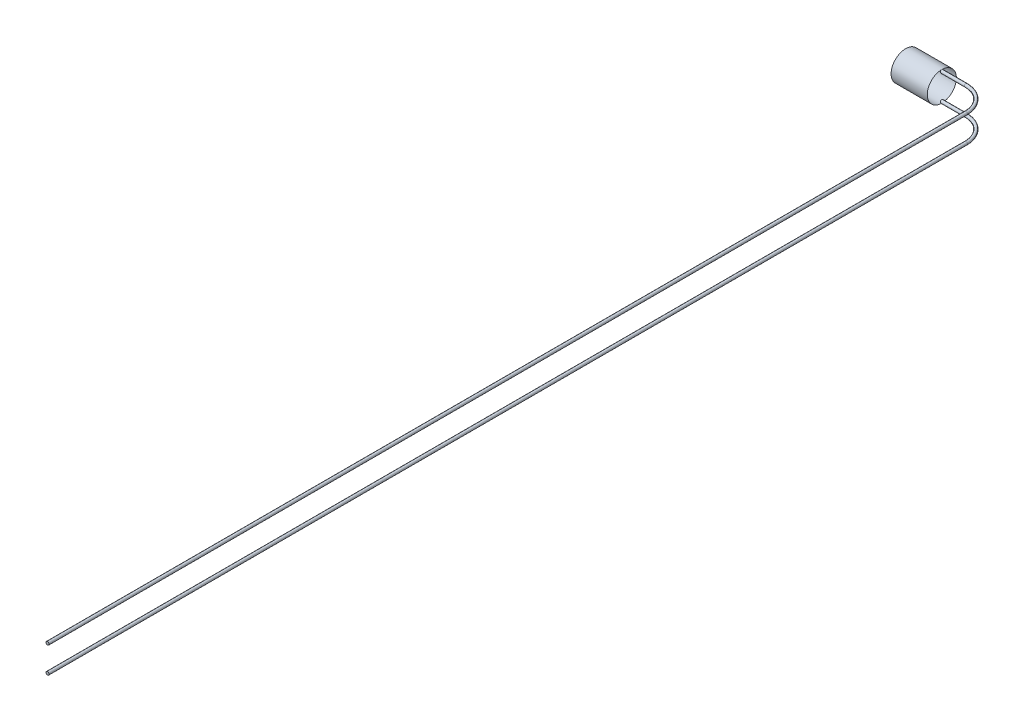
from build123d import *

# Parameters (mm, degrees)
SKETCH1_W = 3
SKETCH1_H = 1.2065
SKETCH2_R = 0.127


with BuildPart() as part:
    # Sketch1 → Revolve1 (revolve)
    with BuildSketch(Plane.XY):
        with Locations((-1.5, 0.60325)):
            Rectangle(SKETCH1_W, SKETCH1_H)
    revolve(axis=Axis((0, 0, 0), (1, 0, 0)))

    # Sweep1: sweep along a path in Sketch3
    with BuildLine(Plane(origin=(0, 0, 0), x_dir=(1, 0, 0), z_dir=(0, 1, 0))) as sweep1_path:
        Line((0, 0), (2, 0))
        ThreePointArc((2, 0), (3.414213562, -0.585786438), (4, -2))
        Line((4, -2), (4, -78.2))
    # Sketch2 → Sweep1 (sweep)
    with BuildSketch(Plane(origin=(0, 0, 0), x_dir=(0, 0, -1), z_dir=(1, 0, 0))):
        with Locations((0, 1.0795)):
            Circle(SKETCH2_R)
        with Locations((0, -1.0795)):
            Circle(SKETCH2_R)
    sweep(path=sweep1_path.line)


solid = part.part
